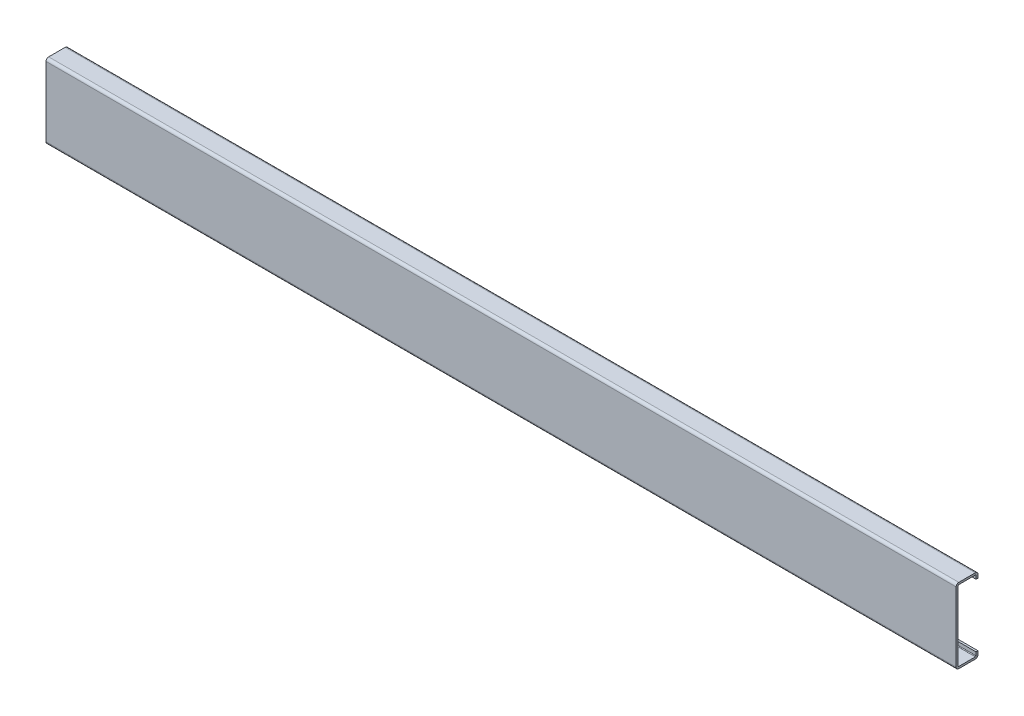
from build123d import *

# Parameters (mm, degrees)
EXTRUDE_1_DEPTH = 550


with BuildPart() as part:
    # Эскиз1 → Вытянуть-Тонкостенный1 (new body)
    with BuildSketch(Plane(origin=(0, 0, 0), x_dir=(0, 0, -1), z_dir=(1, 0, 0))):
        with BuildLine():
            Line((11.4, -19), (11.4, -21))
            ThreePointArc((11.4, -21), (11.282842712, -21.282842712), (11, -21.4))
            Line((11, -21.4), (1, -21.4))
            ThreePointArc((1, -21.4), (0.717157288, -21.282842712), (0.6, -21))
            Line((0.6, -21), (0.6, 21))
            ThreePointArc((0.6, 21), (0.717157288, 21.282842712), (1, 21.4))
            Line((1, 21.4), (11, 21.4))
            ThreePointArc((11, 21.4), (11.282842712, 21.282842712), (11.4, 21))
            Line((11.4, 21), (11.4, 19))
            Line((11.4, 19), (12.6, 19))
            Line((12.6, 19), (12.6, 21))
            ThreePointArc((12.6, 21), (12.13137085, 22.13137085), (11, 22.6))
            Line((11, 22.6), (1, 22.6))
            ThreePointArc((1, 22.6), (-0.13137085, 22.13137085), (-0.6, 21))
            Line((-0.6, 21), (-0.6, -21))
            ThreePointArc((-0.6, -21), (-0.13137085, -22.13137085), (1, -22.6))
            Line((1, -22.6), (11, -22.6))
            ThreePointArc((11, -22.6), (12.13137085, -22.13137085), (12.6, -21))
            Line((12.6, -21), (12.6, -19))
            Line((12.6, -19), (11.4, -19))
        make_face()
    extrude(amount=EXTRUDE_1_DEPTH)


solid = part.part
